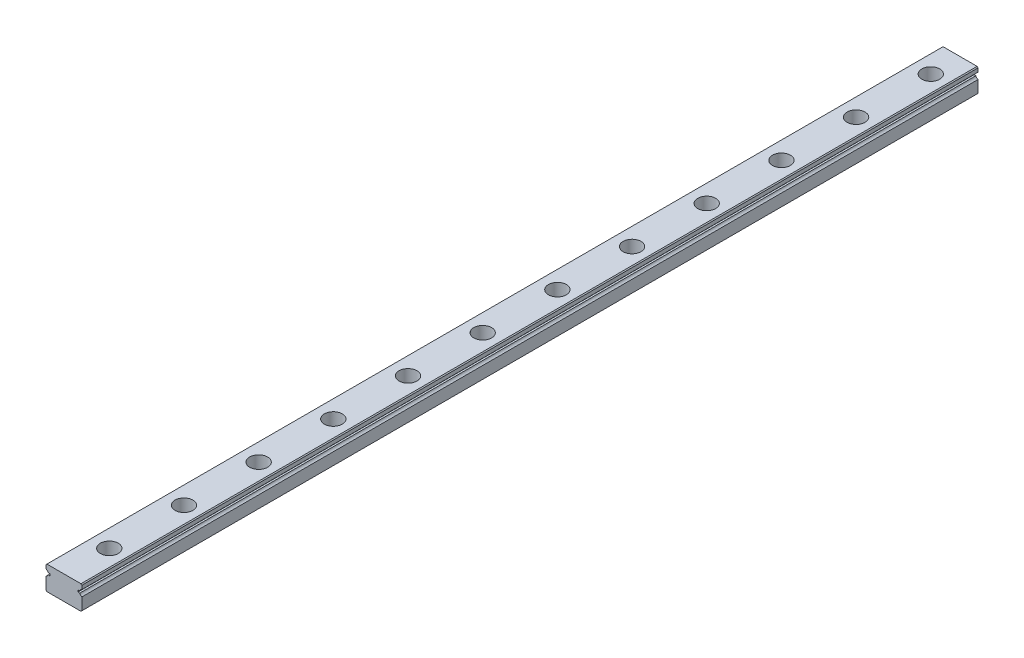
from build123d import *

# Parameters (mm, degrees)
EXTRUDE_1_DEPTH        = 300
SKETCH_2_R             = 3
SKETCH_2_R_2           = 1.75
CUT_EXTRUDE_1_DEPTH    = 4.5
SKETCH_2_2_R           = 1.75
CUT_EXTRUDE_2_DEPTH    = 301.166620396
PATTERN_LINEAR_1_COUNT = 12
PATTERN_LINEAR_1_PITCH = 25


with BuildPart() as part:
    # Эскиз1 → Бобышка-Вытянуть1 (new body)
    with BuildSketch(Plane.XY):
        with BuildLine():
            Line((-6, 3.7), (-5.7, 4))
            Line((-5.7, 4), (5.7, 4))
            Line((5.7, 4), (6, 3.7))
            Line((6, 3.7), (6, 2.449776022))
            ThreePointArc((6, 2.449776022), (5.561887715, 2.168810579), (5.297911886, 1.720256551))
            Line((5.297911886, 1.720256551), (4.687472904, 1.720256551))
            Line((4.687472904, 1.720256551), (4.687472904, 1.082255421))
            Line((4.687472904, 1.082255421), (5.292171789, 1.082255421))
            ThreePointArc((5.292171789, 1.082255421), (5.554928022, 0.621665058), (6, 0.333402583))
            Line((6, 0.333402583), (6, -3.7))
            Line((6, -3.7), (5.7, -4))
            Line((5.7, -4), (-5.7, -4))
            Line((-5.7, -4), (-6, -3.7))
            Line((-6, -3.7), (-6, 0.333402583))
            ThreePointArc((-6, 0.333402583), (-5.554928022, 0.621665058), (-5.292171789, 1.082255421))
            Line((-5.292171789, 1.082255421), (-4.687472904, 1.082255421))
            Line((-4.687472904, 1.082255421), (-4.687472904, 1.720256551))
            Line((-4.687472904, 1.720256551), (-5.297911886, 1.720256551))
            ThreePointArc((-5.297911886, 1.720256551), (-5.561887715, 2.168810579), (-6, 2.449776022))
            Line((-6, 2.449776022), (-6, 3.7))
        make_face()
    extrude(amount=EXTRUDE_1_DEPTH)

    # Эскиз2 → Вырез-Вытянуть1 (cut)
    with BuildSketch(Plane(origin=(0, 4, 0), x_dir=(1, 0, 0), z_dir=(0, 1, 0))):
        with Locations((0.188190244, -10)):
            Circle(SKETCH_2_R)
        with Locations((0.188190244, -10)):
            Circle(SKETCH_2_R_2, mode=Mode.SUBTRACT)
    cut_extrude_1 = extrude(amount=-CUT_EXTRUDE_1_DEPTH, mode=Mode.SUBTRACT)

    # Эскиз2<2> → Вырез-Вытянуть2 (cut, through all)
    with BuildSketch(Plane(origin=(0, 4, 0), x_dir=(1, 0, 0), z_dir=(0, 1, 0))):
        with Locations((0.188190244, -10)):
            Circle(SKETCH_2_2_R)
    cut_extrude_2 = extrude(amount=-CUT_EXTRUDE_2_DEPTH, mode=Mode.SUBTRACT)

    # Линейный массив1: Вырез-Вытянуть1, Вырез-Вытянуть2 ×12
    with Locations(*[(0, 0, i * PATTERN_LINEAR_1_PITCH) for i in range(1, PATTERN_LINEAR_1_COUNT)]):
        add(cut_extrude_1, mode=Mode.SUBTRACT)
        add(cut_extrude_2, mode=Mode.SUBTRACT)


solid = part.part
